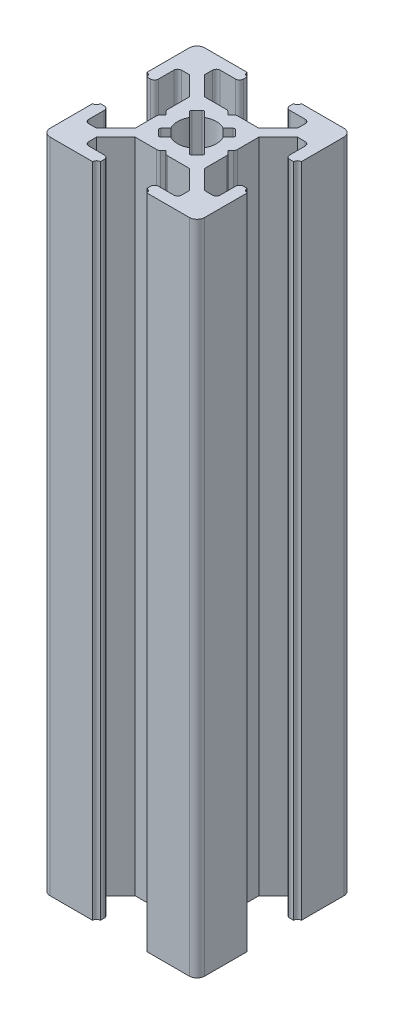
from build123d import *

# Parameters (mm, degrees)
BOSS_EXTRUDE1_DEPTH = 85
FILLET1_R           = 1
CUT_EXTRUDE1_DEPTH  = 86
FILLET2_R           = 0.5
FILLET3_R           = 0.25


with BuildPart() as part:
    # Sketch3 → Boss-Extrude1 (new body)
    with BuildSketch(Plane(origin=(0, 0, 0), x_dir=(1, 0, 0), z_dir=(0, 1, 0))):
        with BuildLine():
            Line((7, 18.5), (7, 19.5))
            ThreePointArc((7, 19.5), (6.646446609, 19.646446609), (6.5, 20))
            Line((6.5, 20), (0, 20))
            Line((0, 20), (0, 13.5))
            ThreePointArc((0, 13.5), (0.353553391, 13.353553391), (0.5, 13))
            Line((0.5, 13), (1.5, 13))
            Line((1.5, 13), (1.5, 16))
            Line((1.5, 16), (3, 16))
            Line((3, 16), (5.5, 13.5))
            Line((5.5, 13.5), (5.5, 10.5))
            Line((5.5, 10.5), (6, 10))
            Line((6, 10), (5.5, 9.5))
            Line((5.5, 9.5), (5.5, 6.5))
            Line((5.5, 6.5), (3, 4))
            Line((3, 4), (1.5, 4))
            Line((1.5, 4), (1.5, 7))
            Line((1.5, 7), (0.5, 7))
            ThreePointArc((0.5, 7), (0.353553391, 6.646446609), (0, 6.5))
            Line((0, 6.5), (0, 0))
            Line((0, 0), (6.5, 0))
            ThreePointArc((6.5, 0), (6.646446609, 0.353553391), (7, 0.5))
            Line((7, 0.5), (7, 1.5))
            Line((7, 1.5), (4, 1.5))
            Line((4, 1.5), (4, 3))
            Line((4, 3), (6.5, 5.5))
            Line((6.5, 5.5), (9.5, 5.5))
            Line((9.5, 5.5), (10, 6))
            Line((10, 6), (10.5, 5.5))
            Line((10.5, 5.5), (13.5, 5.5))
            Line((13.5, 5.5), (16, 3))
            Line((16, 3), (16, 1.5))
            Line((16, 1.5), (13, 1.5))
            Line((13, 1.5), (13, 0.5))
            ThreePointArc((13, 0.5), (13.353553391, 0.353553391), (13.5, 0))
            Line((13.5, 0), (20, 0))
            Line((20, 0), (20, 6.5))
            ThreePointArc((20, 6.5), (19.646446609, 6.646446609), (19.5, 7))
            Line((19.5, 7), (18.5, 7))
            Line((18.5, 7), (18.5, 4))
            Line((18.5, 4), (17, 4))
            Line((17, 4), (14.5, 6.5))
            Line((14.5, 6.5), (14.5, 9.5))
            Line((14.5, 9.5), (14, 10))
            Line((14, 10), (14.5, 10.5))
            Line((14.5, 10.5), (14.5, 13.5))
            Line((14.5, 13.5), (17, 16))
            Line((17, 16), (18.5, 16))
            Line((18.5, 16), (18.5, 13))
            Line((18.5, 13), (19.5, 13))
            ThreePointArc((19.5, 13), (19.646446609, 13.353553391), (20, 13.5))
            Line((20, 13.5), (20, 20))
            Line((20, 20), (13.5, 20))
            ThreePointArc((13.5, 20), (13.353553391, 19.646446609), (13, 19.5))
            Line((13, 19.5), (13, 18.5))
            Line((13, 18.5), (16, 18.5))
            Line((16, 18.5), (16, 17))
            Line((16, 17), (13.5, 14.5))
            Line((13.5, 14.5), (10.5, 14.5))
            Line((10.5, 14.5), (10, 14))
            Line((10, 14), (9.5, 14.5))
            Line((9.5, 14.5), (6.5, 14.5))
            Line((6.5, 14.5), (4, 17))
            Line((4, 17), (4, 18.5))
            Line((4, 18.5), (7, 18.5))
        make_face()
    extrude(amount=BOSS_EXTRUDE1_DEPTH)

    # Fillet1
    fillet1_edges = [part.edges().sort_by_distance(p)[0] for p in [
        (20, 42.5, 0),
        (0, 42.5, 0),
        (0, 42.5, -20),
        (20, 42.5, -20),
    ]]
    fillet(fillet1_edges, radius=FILLET1_R)

    # Sketch4 → Cut-Extrude1 (cut, through all)
    with BuildSketch(Plane(origin=(0, 85, 0), x_dir=(1, 0, 0), z_dir=(0, 1, 0))):
        with BuildLine():
            Line((10, 11), (11.195582496, 12.195582496))
            ThreePointArc((11.195582496, 12.195582496), (10, 12.5), (8.804417504, 12.195582496))
            Line((8.804417504, 12.195582496), (10, 11))
        make_face()
        with BuildLine():
            ThreePointArc((12.195582496, 11.195582496), (11.767766953, 11.767766953), (11.195582496, 12.195582496))
            Line((11.195582496, 12.195582496), (10, 11))
            Line((10, 11), (11, 10))
            Line((11, 10), (12.195582496, 11.195582496))
        make_face()
        with BuildLine():
            Line((9, 10), (10, 11))
            Line((10, 11), (8.804417504, 12.195582496))
            ThreePointArc((8.804417504, 12.195582496), (8.232233047, 11.767766953), (7.804417504, 11.195582496))
            Line((7.804417504, 11.195582496), (9, 10))
        make_face()
        Polygon((11, 10), (10, 11), (9, 10), (10, 9), align=None)
        with BuildLine():
            Line((7.804417504, 8.804417504), (9, 10))
            Line((9, 10), (7.804417504, 11.195582496))
            ThreePointArc((7.804417504, 11.195582496), (7.5, 10), (7.804417504, 8.804417504))
        make_face()
        with BuildLine():
            Line((10, 9), (9, 10))
            Line((9, 10), (7.804417504, 8.804417504))
            ThreePointArc((7.804417504, 8.804417504), (8.232233047, 8.232233047), (8.804417504, 7.804417504))
            Line((8.804417504, 7.804417504), (10, 9))
        make_face()
        with BuildLine():
            Line((11.195582496, 7.804417504), (10, 9))
            Line((10, 9), (8.804417504, 7.804417504))
            ThreePointArc((8.804417504, 7.804417504), (10, 7.5), (11.195582496, 7.804417504))
        make_face()
        with BuildLine():
            Line((12.195582496, 8.804417504), (11, 10))
            Line((11, 10), (10, 9))
            Line((10, 9), (11.195582496, 7.804417504))
            ThreePointArc((11.195582496, 7.804417504), (11.767766953, 8.232233047), (12.195582496, 8.804417504))
        make_face()
        with BuildLine():
            ThreePointArc((12.5, 10), (12.422700584, 10.616864556), (12.195582496, 11.195582496))
            Line((12.195582496, 11.195582496), (11, 10))
            Line((11, 10), (12.195582496, 8.804417504))
            ThreePointArc((12.195582496, 8.804417504), (12.422700584, 9.383135444), (12.5, 10))
        make_face()
        with BuildLine():
            ThreePointArc((8.804417504, 7.804417504), (8.232233047, 8.232233047), (7.804417504, 8.804417504))
            Line((7.804417504, 8.804417504), (7, 8))
            Line((7, 8), (8, 7))
            Line((8, 7), (8.804417504, 7.804417504))
        make_face()
        with BuildLine():
            Line((13, 8), (12.195582496, 8.804417504))
            ThreePointArc((12.195582496, 8.804417504), (11.767766953, 8.232233047), (11.195582496, 7.804417504))
            Line((11.195582496, 7.804417504), (12, 7))
            Line((12, 7), (13, 8))
        make_face()
        with BuildLine():
            Line((13, 12), (12, 13))
            Line((12, 13), (11.195582496, 12.195582496))
            ThreePointArc((11.195582496, 12.195582496), (11.767766953, 11.767766953), (12.195582496, 11.195582496))
            Line((12.195582496, 11.195582496), (13, 12))
        make_face()
        with BuildLine():
            ThreePointArc((7.804417504, 11.195582496), (8.232233047, 11.767766953), (8.804417504, 12.195582496))
            Line((8.804417504, 12.195582496), (8, 13))
            Line((8, 13), (7, 12))
            Line((7, 12), (7.804417504, 11.195582496))
        make_face()
    extrude(amount=-CUT_EXTRUDE1_DEPTH, mode=Mode.SUBTRACT)

    # Fillet2
    fillet2_edges = [part.edges().sort_by_distance(p)[0] for p in [
        (18.5, 42.5, -13),
        (18.5, 42.5, -16),
        (14.5, 42.5, -10.5),
        (14.5, 42.5, -9.5),
        (18.5, 42.5, -4),
        (18.5, 42.5, -7),
        (13, 42.5, -1.5),
        (16, 42.5, -1.5),
        (10.5, 42.5, -5.5),
        (9.5, 42.5, -5.5),
        (4, 42.5, -1.5),
        (7, 42.5, -1.5),
        (1.5, 42.5, -7),
        (1.5, 42.5, -4),
        (5.5, 42.5, -9.5),
        (5.5, 42.5, -10.5),
        (1.5, 42.5, -16),
        (1.5, 42.5, -13),
        (7, 42.5, -18.5),
        (4, 42.5, -18.5),
        (9.5, 42.5, -14.5),
        (10.5, 42.5, -14.5),
        (16, 42.5, -18.5),
        (13, 42.5, -18.5),
    ]]
    fillet(fillet2_edges, radius=FILLET2_R)

    # Fillet3
    fillet3_edges = [part.edges().sort_by_distance(p)[0] for p in [
        (7, 42.5, -12),
        (8, 42.5, -13),
        (12, 42.5, -13),
        (13, 42.5, -12),
        (13, 42.5, -8),
        (12, 42.5, -7),
        (8, 42.5, -7),
        (7, 42.5, -8),
    ]]
    fillet(fillet3_edges, radius=FILLET3_R)


solid = part.part
